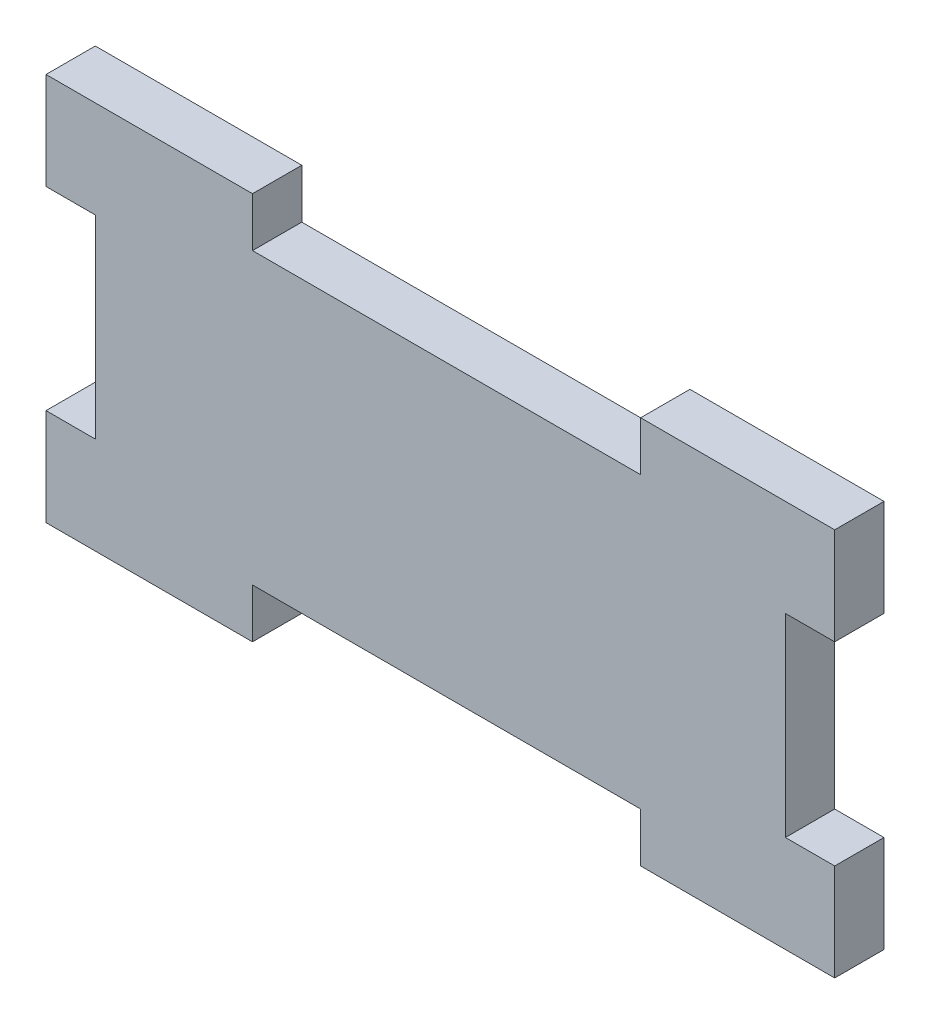
from build123d import *

# Parameters (mm, degrees)
SKETCH1_W           = 101.6
SKETCH1_H           = 50
BOSS_EXTRUDE1_DEPTH = 6.35
SKETCH3_W           = 6.35
SKETCH3_H           = 25
CUT_EXTRUDE2_DEPTH  = 7.35
SKETCH4_W           = 6.35
SKETCH4_H           = 25
SKETCH4_W_2         = 50
SKETCH4_H_2         = 6.35
CUT_EXTRUDE3_DEPTH  = 7.35


with BuildPart() as part:
    # Sketch1 → Boss-Extrude1 (new body)
    with BuildSketch(Plane.XY):
        with Locations((50.8, 25)):
            Rectangle(SKETCH1_W, SKETCH1_H)
    extrude(amount=BOSS_EXTRUDE1_DEPTH)

    # Sketch3 → Cut-Extrude2 (cut, through all)
    with BuildSketch(Plane.XY.offset(6.35)):
        with Locations((3.175, 25)):
            Rectangle(SKETCH3_W, SKETCH3_H)
    extrude(amount=-CUT_EXTRUDE2_DEPTH, mode=Mode.SUBTRACT)

    # Sketch4 → Cut-Extrude3 (cut, through all)
    with BuildSketch(Plane.XY.offset(6.35)):
        with Locations((98.425, 25)):
            Rectangle(SKETCH4_W, SKETCH4_H)
        with Locations((51.6, 46.825)):
            Rectangle(SKETCH4_W_2, SKETCH4_H_2)
        with Locations((51.6, 3.175)):
            Rectangle(SKETCH4_W_2, SKETCH4_H_2)
    extrude(amount=-CUT_EXTRUDE3_DEPTH, mode=Mode.SUBTRACT)


solid = part.part
